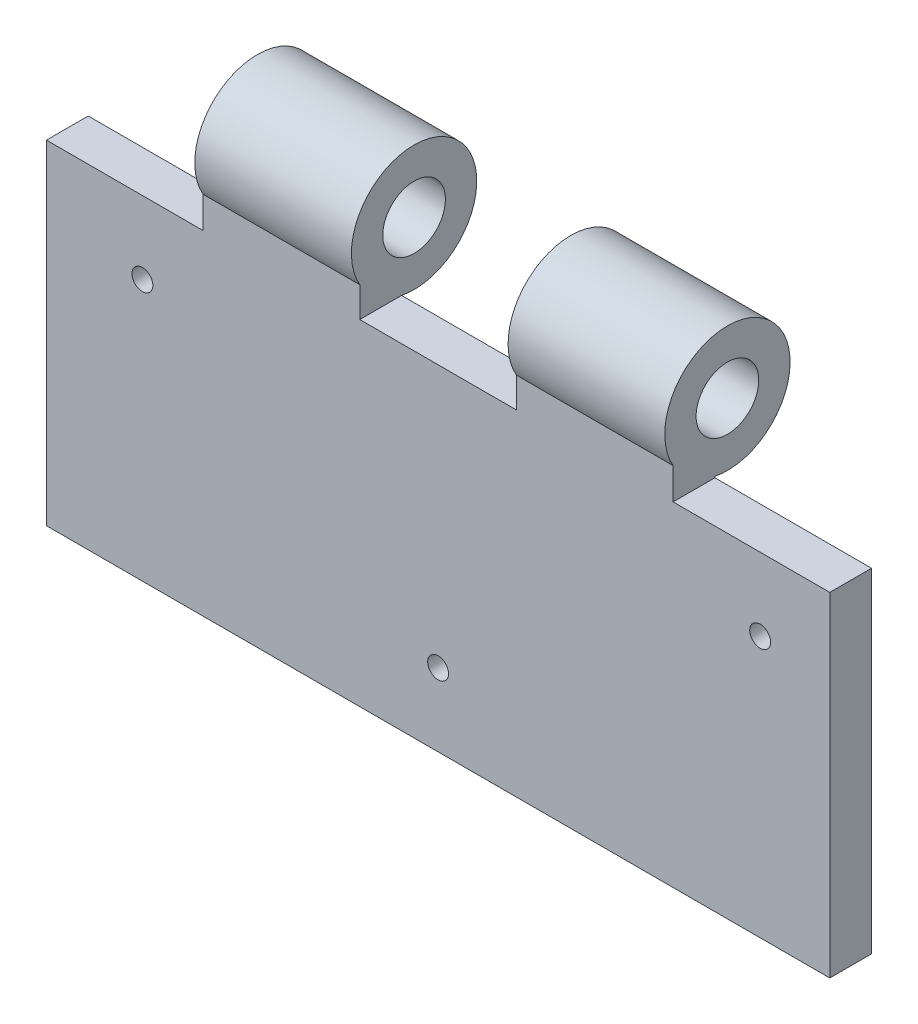
from build123d import *

# Parameters (mm, degrees)
SKETCH1_W           = 150
SKETCH1_H           = 70
BOSS_EXTRUDE1_DEPTH = 4
SKETCH7_R           = 2
CUT_EXTRUDE2_DEPTH  = 30
BOSS_EXTRUDE7_START = -30
SKETCH4_R           = 12
SKETCH4_R_2         = 6
BOSS_EXTRUDE7_DEPTH = 30
LPATTERN2_COUNT     = 2
LPATTERN2_PITCH     = 60
CHAMFER3_SIZE       = 4
SKETCH8_W           = 30
SKETCH8_H           = 6.046246811
CUT_EXTRUDE3_DEPTH  = 10
SKETCH9_W           = 30
SKETCH9_H           = 6.046246811
CUT_EXTRUDE4_DEPTH  = 10
SKETCH10_W          = 30
SKETCH10_H          = 5.803707669
CUT_EXTRUDE5_DEPTH  = 10


with BuildPart() as part:
    # Sketch1 → Boss-Extrude1 (new body, symmetric)
    with BuildSketch(Plane.XY):
        Rectangle(SKETCH1_W, SKETCH1_H)
    extrude(amount=BOSS_EXTRUDE1_DEPTH, both=True)

    # Sketch7 → Cut-Extrude2 (cut)
    with BuildSketch(Plane.XY.offset(4)):
        with Locations((-56.630501899, 15.015863732)):
            Circle(SKETCH7_R)
        with Locations((0, -21.058085924)):
            Circle(SKETCH7_R)
        with Locations((61.669656729, 15.015863732)):
            Circle(SKETCH7_R)
    extrude(amount=-CUT_EXTRUDE2_DEPTH, mode=Mode.SUBTRACT)

    # Sketch4 → Boss-Extrude7 (add)
    with BuildSketch(Plane(origin=(75, 0, 0), x_dir=(0, 0, -1), z_dir=(1, 0, 0)).offset(BOSS_EXTRUDE7_START)):
        with Locations((6.400440408, 40.953753189)):
            Circle(SKETCH4_R)
        with Locations((6.400440408, 40.953753189)):
            Circle(SKETCH4_R_2, mode=Mode.SUBTRACT)
    boss_extrude7 = extrude(amount=-BOSS_EXTRUDE7_DEPTH)

    # LPattern2: Boss-Extrude7 ×2
    with Locations(*[(-i * LPATTERN2_PITCH, 0, 0) for i in range(1, LPATTERN2_COUNT)]):
        add(boss_extrude7)

    # Chamfer3
    chamfer3_edges = [part.edges().sort_by_distance(p)[0] for p in [
        (-58.630501899, 15.015863732, -4),
        (-2, -21.058085924, -4),
        (59.669656729, 15.015863732, -4),
    ]]
    chamfer(chamfer3_edges, length=CHAMFER3_SIZE)

    # Sketch8 → Cut-Extrude3 (cut)
    with BuildSketch(Plane.XY.offset(4)):
        with Locations((60, 31.976876594)):
            Rectangle(SKETCH8_W, SKETCH8_H)
    extrude(amount=-CUT_EXTRUDE3_DEPTH, mode=Mode.SUBTRACT)

    # Sketch9 → Cut-Extrude4 (cut)
    with BuildSketch(Plane(origin=(0, 0, -4), x_dir=(-1, 0, 0), z_dir=(0, 0, -1))):
        with Locations((60, 31.976876594)):
            Rectangle(SKETCH9_W, SKETCH9_H)
    extrude(amount=-CUT_EXTRUDE4_DEPTH, mode=Mode.SUBTRACT)

    # Sketch10 → Cut-Extrude5 (cut)
    with BuildSketch(Plane(origin=(0, 0, -4), x_dir=(-1, 0, 0), z_dir=(0, 0, -1))):
        with Locations((0, 32.098146165)):
            Rectangle(SKETCH10_W, SKETCH10_H)
    extrude(amount=-CUT_EXTRUDE5_DEPTH, mode=Mode.SUBTRACT)


solid = part.part
